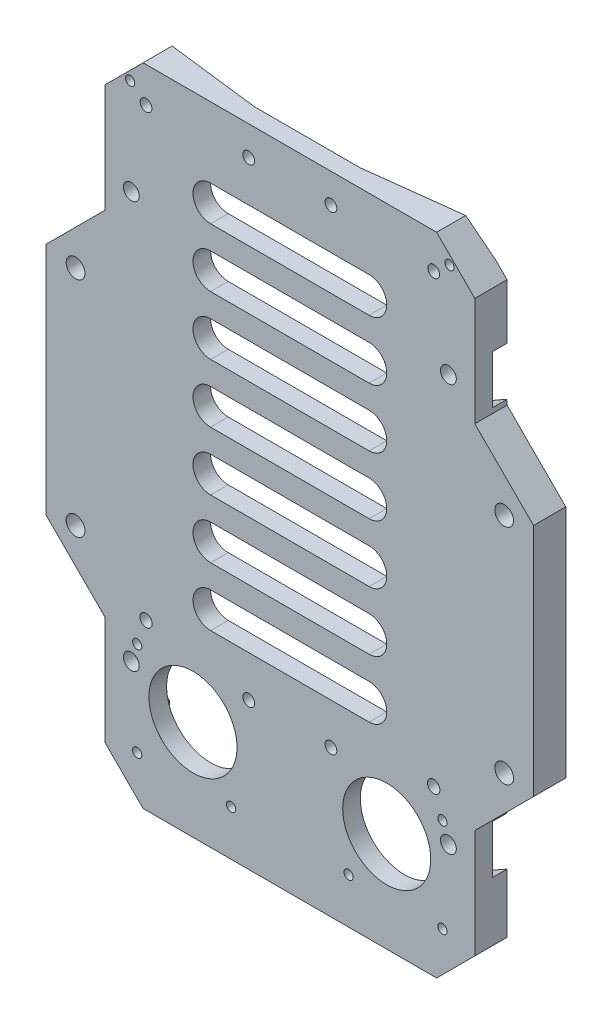
from build123d import *

# Parameters (mm, degrees)
EXTRUDE_1_DEPTH     = 110
SKETCH_3_R          = 1.35
CUT_EXTRUDE_2_DEPTH = 110
CUT_EXTRUDE_3_DEPTH = 65
SKETCH1_R           = 0.785
SKETCH1_R_2         = 1
SKETCH1_R_3         = 1.05
CUT_EXTRUDE1_DEPTH  = 10
SKETCH2_W           = 70.969328166
SKETCH2_H           = 159.698844539
CUT_EXTRUDE2_DEPTH  = 10
BOSS_EXTRUDE1_DEPTH = 5.5
SKETCH4_R           = 1.6
CUT_EXTRUDE3_DEPTH  = 20
CHAMFER1_SIZE       = 6.5
SKETCH5_R           = 7.5
CUT_EXTRUDE4_DEPTH  = 10


with BuildPart() as part:
    # 草图1 → 凸台-拉伸1 (new body)
    with BuildSketch(Plane(origin=(0, 0, 0), x_dir=(1, 0, 0), z_dir=(0, 1, 0))):
        Polygon((-46.858999723, -0.34362784), (-46.858999723, 2.65637216), (-24.358999723, -0.08362784), (-6.358999723, -0.08362784), (16.141000277, 2.660274599), (16.141000277, -0.34362784), (16.141000277, -3.08362784), (-6.358999723, -3.08362784), (-24.358999723, -3.08362784), (-46.858999723, -3.08362784), align=None)
    extrude(amount=EXTRUDE_1_DEPTH)

    # 草图3 → 切除-拉伸2 (cut)
    with BuildSketch(Plane.XY.offset(3.08362784)):
        with Locations((11.641000277, 90)):
            Circle(SKETCH_3_R)
        with Locations((11.641000277, 20.7)):
            Circle(SKETCH_3_R)
        with Locations((-42.358999723, 20.7)):
            Circle(SKETCH_3_R)
        with Locations((-42.358999723, 90)):
            Circle(SKETCH_3_R)
    extrude(amount=-CUT_EXTRUDE_2_DEPTH, mode=Mode.SUBTRACT)

    # 草图4 → 切除-拉伸3 (cut)
    with BuildSketch(Plane(origin=(0, 0, 0.08362784), x_dir=(-1, 0, 0), z_dir=(0, 0, -1))):
        Polygon((40.908999723, 6.9), (40.908999723, 13.2), (47.093892861, 16.7), (47.093892861, 24.7), (40.908999723, 28.2), (40.908999723, 82.5), (47.093892861, 86), (47.093892861, 94), (40.908999723, 97.5), (40.908999723, 103.8), (-10.191000277, 103.8), (-10.191000277, 97.5), (-16.375893416, 94), (-16.375893416, 86), (-10.191000277, 82.5), (-10.191000277, 28.2), (-16.375893416, 24.7), (-16.375893416, 16.7), (-10.191000277, 13.2), (-10.191000277, 6.9), align=None)
    extrude(amount=CUT_EXTRUDE_3_DEPTH, mode=Mode.SUBTRACT)

    # Sketch1 → Cut-Extrude1 (cut)
    with BuildSketch(Plane.XY.offset(3.08362784)):
        with Locations((-42.558897723, 106.265557005)):
            Circle(SKETCH1_R)
        with Locations((-39.858893724, 103.999988001)):
            Circle(SKETCH1_R_2)
        with Locations((-22.358833723, 105)):
            Circle(SKETCH1_R_2)
        with Locations((-22.358833723, 25)):
            Circle(SKETCH1_R_2)
        with Locations((-39.858893724, 27.999986001)):
            Circle(SKETCH1_R_3)
        with Locations((-41.358999723, 23.749988001)):
            Circle(SKETCH1_R)
        with Locations((-41.358999723, 7.749988001)):
            Circle(SKETCH1_R)
        with Locations((-25.358999723, 7.749988001)):
            Circle(SKETCH1_R)
        with Locations((-5.358999723, 7.749988001)):
            Circle(SKETCH1_R)
        with Locations((10.641000277, 7.749988001)):
            Circle(SKETCH1_R)
        with Locations((10.641000277, 23.749988001)):
            Circle(SKETCH1_R)
        with Locations((9.140894279, 27.999986001)):
            Circle(SKETCH1_R_3)
        with Locations((-8.359165723, 25)):
            Circle(SKETCH1_R_2)
        with Locations((-8.359165723, 105)):
            Circle(SKETCH1_R_2)
        with Locations((9.140894279, 103.999988001)):
            Circle(SKETCH1_R_2)
        with Locations((11.840898278, 106.265557005)):
            Circle(SKETCH1_R)
    extrude(amount=-CUT_EXTRUDE1_DEPTH, mode=Mode.SUBTRACT)

    # Sketch2 → Cut-Extrude2 (cut)
    with BuildSketch(Plane(origin=(0, 0, -2.41637216), x_dir=(-1, 0, 0), z_dir=(0, 0, -1))):
        with Locations((16.341269992, 58.054935109)):
            Rectangle(SKETCH2_W, SKETCH2_H)
    extrude(amount=CUT_EXTRUDE2_DEPTH, mode=Mode.SUBTRACT)

    # Sketch3 → Boss-Extrude1 (add)
    with BuildSketch(Plane.XY.offset(3.08362784)):
        Polygon((-46.858999723, 85), (-56.858999723, 75), (-56.858999723, 35), (-46.858999723, 25), align=None)
        Polygon((16.141000277, 85), (16.141000277, 25), (26.141000277, 35), (26.141000277, 75), align=None)
    extrude(amount=-BOSS_EXTRUDE1_DEPTH)

    # Sketch4 → Cut-Extrude3 (cut)
    with BuildSketch(Plane(origin=(0, 0, -2.41637216), x_dir=(-1, 0, 0), z_dir=(0, 0, -1))):
        with Locations((-21.141000277, 74)):
            Circle(SKETCH4_R)
        with Locations((-21.141000277, 36)):
            Circle(SKETCH4_R)
        with Locations((51.858999723, 74)):
            Circle(SKETCH4_R)
        with Locations((51.858999723, 36)):
            Circle(SKETCH4_R)
    extrude(amount=-CUT_EXTRUDE3_DEPTH, mode=Mode.SUBTRACT)

    # Chamfer1
    chamfer1_edges = [part.edges().sort_by_distance(p)[0] for p in [
        (16.141000277, 110, 0.33362784),
        (-46.858999723, 110, 0.33362784),
        (16.141000277, 0, 0.33362784),
        (-46.858999723, 0, 0.33362784),
    ]]
    chamfer(chamfer1_edges, length=CHAMFER1_SIZE)

    # Sketch5 → Cut-Extrude4 (cut)
    with BuildSketch(Plane(origin=(0, 0, 0.08362784), x_dir=(-1, 0, 0), z_dir=(0, 0, -1))):
        with Locations((31.858999723, 17)):
            Circle(SKETCH5_R)
        with Locations((-1.141000277, 17)):
            Circle(SKETCH5_R)
        with BuildLine():
            Line((28.858999723, 32), (1.858999723, 32))
            ThreePointArc((1.858999723, 32), (-1.141000277, 35), (1.858999723, 38))
            Line((1.858999723, 38), (28.858999723, 38))
            ThreePointArc((28.858999723, 38), (31.858999723, 35), (28.858999723, 32))
        make_face()
        with BuildLine():
            Line((28.858999723, 42), (1.858999723, 42))
            ThreePointArc((1.858999723, 42), (-1.141000277, 45), (1.858999723, 48))
            Line((1.858999723, 48), (28.858999723, 48))
            ThreePointArc((28.858999723, 48), (31.858999723, 45), (28.858999723, 42))
        make_face()
        with BuildLine():
            Line((28.858999723, 52), (1.858999723, 52))
            ThreePointArc((1.858999723, 52), (-1.141000277, 55), (1.858999723, 58))
            Line((1.858999723, 58), (28.858999723, 58))
            ThreePointArc((28.858999723, 58), (31.858999723, 55), (28.858999723, 52))
        make_face()
        with BuildLine():
            Line((28.858999723, 62), (1.858999723, 62))
            ThreePointArc((1.858999723, 62), (-1.141000277, 65), (1.858999723, 68))
            Line((1.858999723, 68), (28.858999723, 68))
            ThreePointArc((28.858999723, 68), (31.858999723, 65), (28.858999723, 62))
        make_face()
        with BuildLine():
            Line((28.858999723, 72), (1.858999723, 72))
            ThreePointArc((1.858999723, 72), (-1.141000277, 75), (1.858999723, 78))
            Line((1.858999723, 78), (28.858999723, 78))
            ThreePointArc((28.858999723, 78), (31.858999723, 75), (28.858999723, 72))
        make_face()
        with BuildLine():
            Line((28.858999723, 82), (1.858999723, 82))
            ThreePointArc((1.858999723, 82), (-1.141000277, 85), (1.858999723, 88))
            Line((1.858999723, 88), (28.858999723, 88))
            ThreePointArc((28.858999723, 88), (31.858999723, 85), (28.858999723, 82))
        make_face()
        with BuildLine():
            Line((28.858999723, 92), (1.858999723, 92))
            ThreePointArc((1.858999723, 92), (-1.141000277, 95), (1.858999723, 98))
            Line((1.858999723, 98), (28.858999723, 98))
            ThreePointArc((28.858999723, 98), (31.858999723, 95), (28.858999723, 92))
        make_face()
    extrude(amount=-CUT_EXTRUDE4_DEPTH, mode=Mode.SUBTRACT)


solid = part.part
